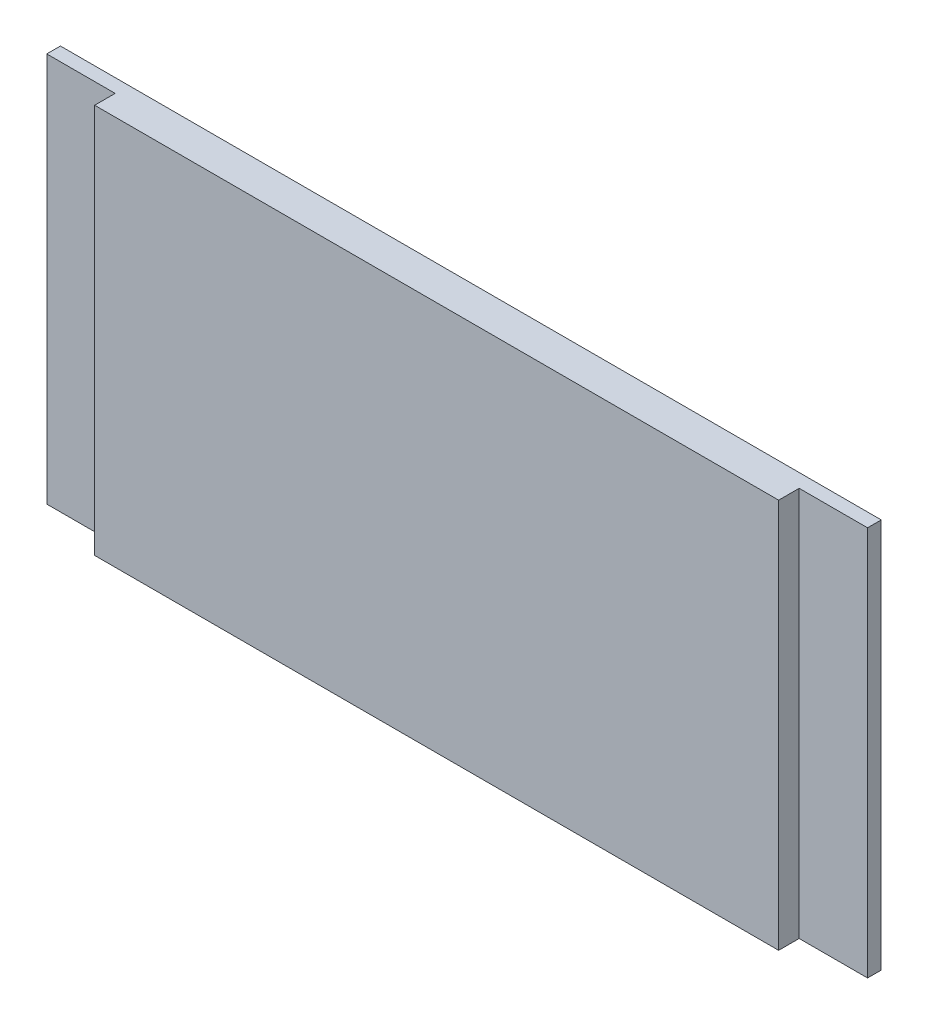
from build123d import *

# Parameters (mm, degrees)
SKETCH1_W           = 100
SKETCH1_H           = 57
BOSS_EXTRUDE1_DEPTH = 5
SKETCH1_3_W         = 10
SKETCH1_3_H         = 57
BOSS_EXTRUDE2_DEPTH = 2


with BuildPart() as part:
    # Sketch1 → Boss-Extrude1 (new body)
    with BuildSketch(Plane.XY):
        Rectangle(SKETCH1_W, SKETCH1_H)
    extrude(amount=BOSS_EXTRUDE1_DEPTH)

    # Sketch1_3 → Boss-Extrude2 (add)
    with BuildSketch(Plane.XY):
        with Locations((-55, 0)):
            Rectangle(SKETCH1_3_W, SKETCH1_3_H)
        with Locations((55, 0)):
            Rectangle(SKETCH1_3_W, SKETCH1_3_H)
    extrude(amount=BOSS_EXTRUDE2_DEPTH)


solid = part.part
